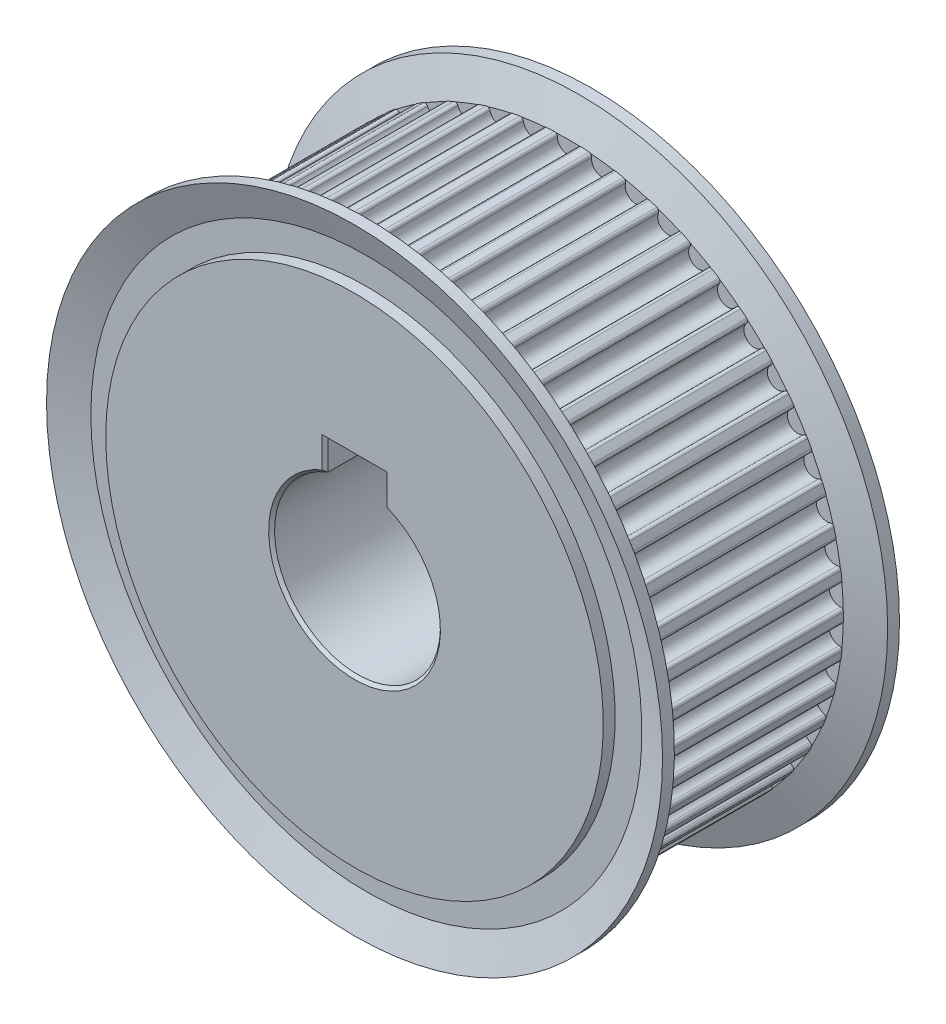
from build123d import *

# Parameters (mm, degrees)
SKETCH1_R                  = 23.875
BASE_DEPTH                 = 8
TOOTHCUT_DEPTH             = 9
TEETHCUTS_COUNT            = 50
BORE_AND_KEYWAY_DEPTH      = 11
BORE_AND_KEYWAY_DEPTH_BACK = 11
BORECHAMFER_SIZE           = 0.25


with BuildPart() as part:
    # Sketch1 → Base (new body, symmetric)
    with BuildSketch(Plane.XY):
        Circle(SKETCH1_R)
    extrude(amount=BASE_DEPTH, both=True)

    # Sketch2 → ToothCut (cut, symmetric)
    with BuildSketch(Plane.XY):
        with BuildLine():
            Line((-1.461222555, 23.239106128), (-1.498247305, 23.82794326))
            ThreePointArc((-1.498247305, 23.82794326), (0.00087808, 23.874999984), (1.5, 23.82783299))
            Line((1.5, 23.82783299), (1.462931937, 23.238998583))
            ThreePointArc((1.462931937, 23.238998583), (1.297459585, 23.248824134), (1.13192148, 23.257471461))
            ThreePointArc((1.13192148, 23.257471461), (0.945511035, 23.187027474), (0.869820233, 23.002685097))
            ThreePointArc((0.869820233, 23.002685097), (0, 22.115), (-0.869820233, 23.002685097))
            ThreePointArc((-0.869820233, 23.002685097), (-0.945511035, 23.187027474), (-1.13192148, 23.257471461))
            ThreePointArc((-1.13192148, 23.257471461), (-1.296604534, 23.248871837), (-1.461222555, 23.239106128))
        make_face()
    toothcut = extrude(amount=TOOTHCUT_DEPTH, both=True, mode=Mode.SUBTRACT)

    # TeethCuts: ToothCut ×50 about axis
    teethcuts_axis = Axis((0, 0, 0), (0, 0, 1))
    for i in range(1, TEETHCUTS_COUNT):
        add(toothcut.rotate(teethcuts_axis, i * 360 / TEETHCUTS_COUNT), mode=Mode.SUBTRACT)

    # Sketch6 → Flange (revolve)
    with BuildSketch(Plane(origin=(0, 0, 0), x_dir=(0, 0, -1), z_dir=(1, 0, 0))):
        Polygon((-8, 23.257471461), (-9, 26), (-10, 26), (-9, 23.257471461), (-9, 21), (-10, 21), (-10, 0), (-8, 0), align=None)
        Polygon((8, 0), (8, 23.257471461), (9, 26), (10, 26), (9, 23.257471461), (9, 21), (10, 21), (10, 0), align=None)
    revolve(axis=Axis((0, 0, -8), (0, 0, 1)))

    # Sketch7 → Bore and Keyway (cut, two sides)
    with BuildSketch(Plane.XY) as bore_and_keyway_sk:
        with BuildLine():
            Line((-2.485, 9.044064104), (2.485, 9.044064104))
            Line((2.485, 9.044064104), (2.485, 6.544064104))
            ThreePointArc((2.485, 6.544064104), (0, -7), (-2.485, 6.544064104))
            Line((-2.485, 6.544064104), (-2.485, 9.044064104))
        make_face()
    extrude(amount=BORE_AND_KEYWAY_DEPTH, mode=Mode.SUBTRACT)
    extrude(bore_and_keyway_sk.sketch, amount=-BORE_AND_KEYWAY_DEPTH_BACK, mode=Mode.SUBTRACT)

    # BoreChamfer
    borechamfer_edges = [part.edges().sort_by_distance(p)[0] for p in [
        (-2.485, 7.794064104, -10),
        (0, 9.044064104, -10),
        (2.485, 7.794064104, -10),
        (0, -7, -10),
        (-2.485, 7.794064104, 10),
        (0, -7, 10),
        (2.485, 7.794064104, 10),
        (0, 9.044064104, 10),
    ]]
    chamfer(borechamfer_edges, length=BORECHAMFER_SIZE)


solid = part.part
